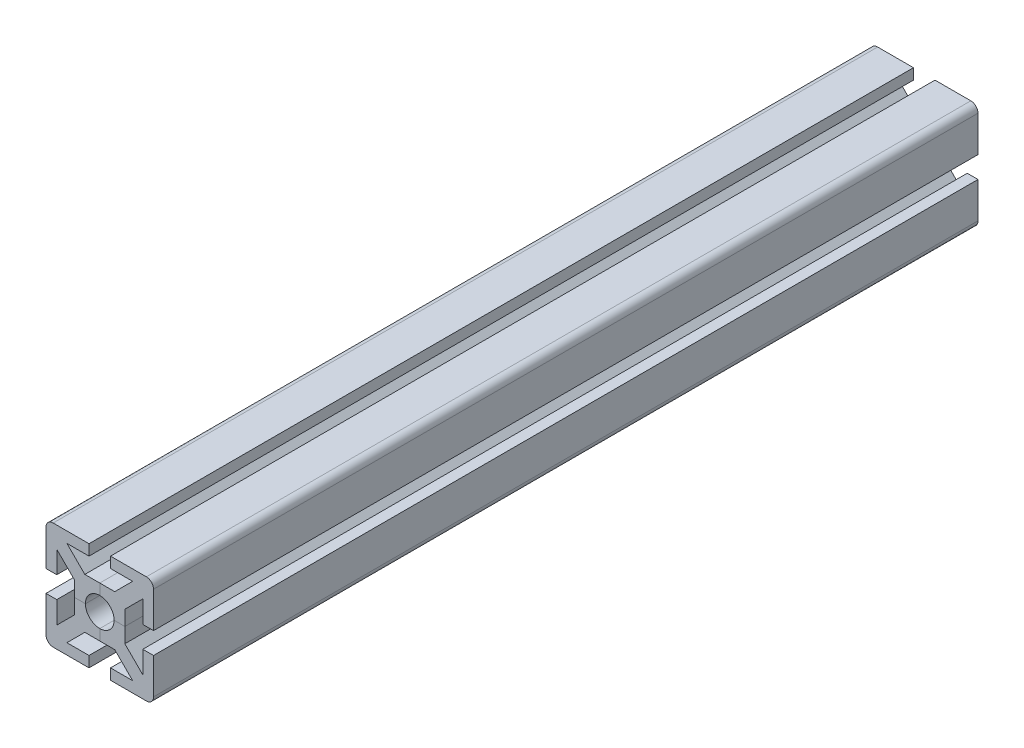
from build123d import *

# Parameters (mm, degrees)
SALIENTE_EXTRUIR1_DEPTH = 115
REDONDEO1_R             = 2
MATRIZC4_COUNT          = 4


with BuildPart() as part:
    # Croquis1 → Saliente-Extruir1 (new body, symmetric)
    with BuildSketch(Plane.XY):
        with BuildLine():
            Line((0, 4), (0, 7))
            Line((0, 7), (4.171572875, 7))
            Line((4.171572875, 7), (9.171572875, 12))
            Line((9.171572875, 12), (3, 12))
            Line((3, 12), (3, 15))
            Line((3, 15), (15, 15))
            Line((15, 15), (2.828427125, 2.828427125))
            ThreePointArc((2.828427125, 2.828427125), (1.530733729, 3.69551813), (0, 4))
        make_face()
    saliente_extruir1 = extrude(amount=SALIENTE_EXTRUIR1_DEPTH, both=True)

    # Simetría1: Saliente-Extruir1 across plane
    add(saliente_extruir1.mirror(Plane(origin=(2.828427125, 2.828427125, 115), x_dir=(0, 0, 1), z_dir=(-0.707106781, 0.707106781, 0))))

    # Redondeo1
    redondeo1_edges = [part.edges().sort_by_distance(p)[0] for p in [
        (15, 15, 0),
    ]]
    fillet(redondeo1_edges, radius=REDONDEO1_R)


with BuildPart() as matrizc4_1:
    # MatrizC4: pattern copy
    add(part.part.rotate(Axis((0, 0, 0), (0, 0, 1)), 1 * 360 / MATRIZC4_COUNT))


with BuildPart() as matrizc4_2:
    # MatrizC4: pattern copy
    add(part.part.rotate(Axis((0, 0, 0), (0, 0, 1)), 2 * 360 / MATRIZC4_COUNT))


with BuildPart() as matrizc4_3:
    # MatrizC4: pattern copy
    add(part.part.rotate(Axis((0, 0, 0), (0, 0, 1)), 3 * 360 / MATRIZC4_COUNT))


solid = Compound([part.part, matrizc4_1.part, matrizc4_2.part, matrizc4_3.part])
